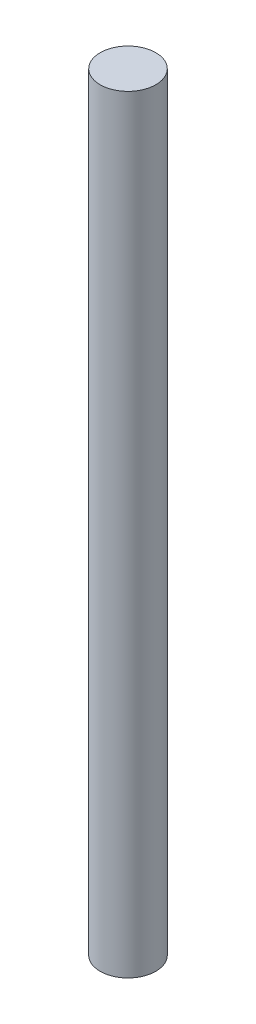
from build123d import *

# Parameters (mm, degrees)
SKETCH1_R           = 8
BOSS_EXTRUDE1_DEPTH = 221


with BuildPart() as part:
    # Sketch1 → Boss-Extrude1 (new body)
    with BuildSketch(Plane(origin=(0, 0, 0), x_dir=(1, 0, 0), z_dir=(0, 1, 0))):
        Circle(SKETCH1_R)
    extrude(amount=BOSS_EXTRUDE1_DEPTH)


solid = part.part
